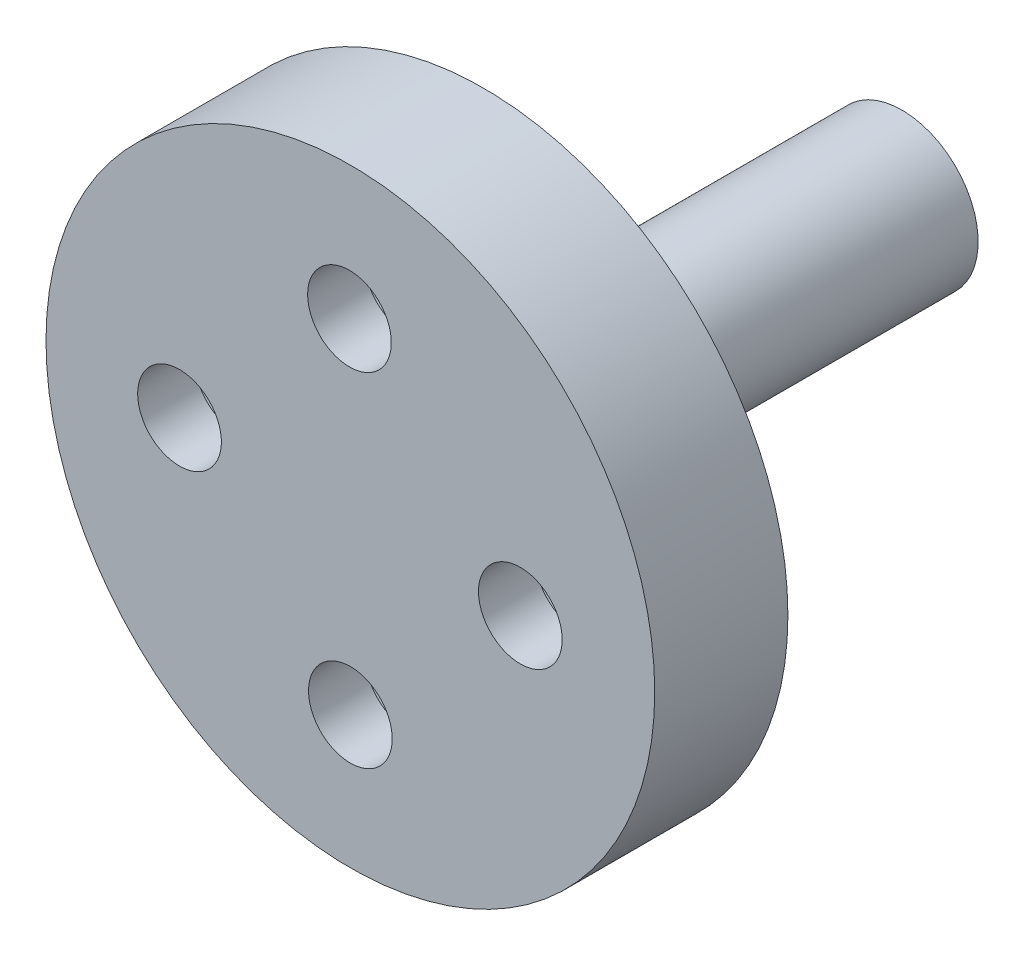
from build123d import *

# Parameters (mm, degrees)
CBORE_FOR_M2_SHCS2_D           = 2.2
CBORE_FOR_M2_SHCS2_CBORE_D     = 4.4
CBORE_FOR_M2_SHCS2_CBORE_DEPTH = 2


with BuildPart() as part:
    # Sketch1 → Revolve1 (revolve)
    with BuildSketch(Plane(origin=(0, 0, 0), x_dir=(1, 0, 0), z_dir=(0, 1, 0))):
        Polygon((0, 0), (8, 0), (8, 3.5), (2, 3.5), (2, 14.5), (0, 14.5), align=None)
    revolve(axis=Axis((0, 0, -14.5), (0, 0, 1)))

    # CBORE for M2 SHCS2 (through all)
    with Locations(Plane(origin=(0, 0, -3.5), x_dir=(-1, 0, 0), z_dir=(0, 0, -1))):
        with Locations((4.49122807, 0), (0.023889511, 4.49122807), (-4.467338559, -0.023889511), (0, -4.515117581)):
            CounterBoreHole(CBORE_FOR_M2_SHCS2_D / 2, CBORE_FOR_M2_SHCS2_CBORE_D / 2, CBORE_FOR_M2_SHCS2_CBORE_DEPTH)


solid = part.part
